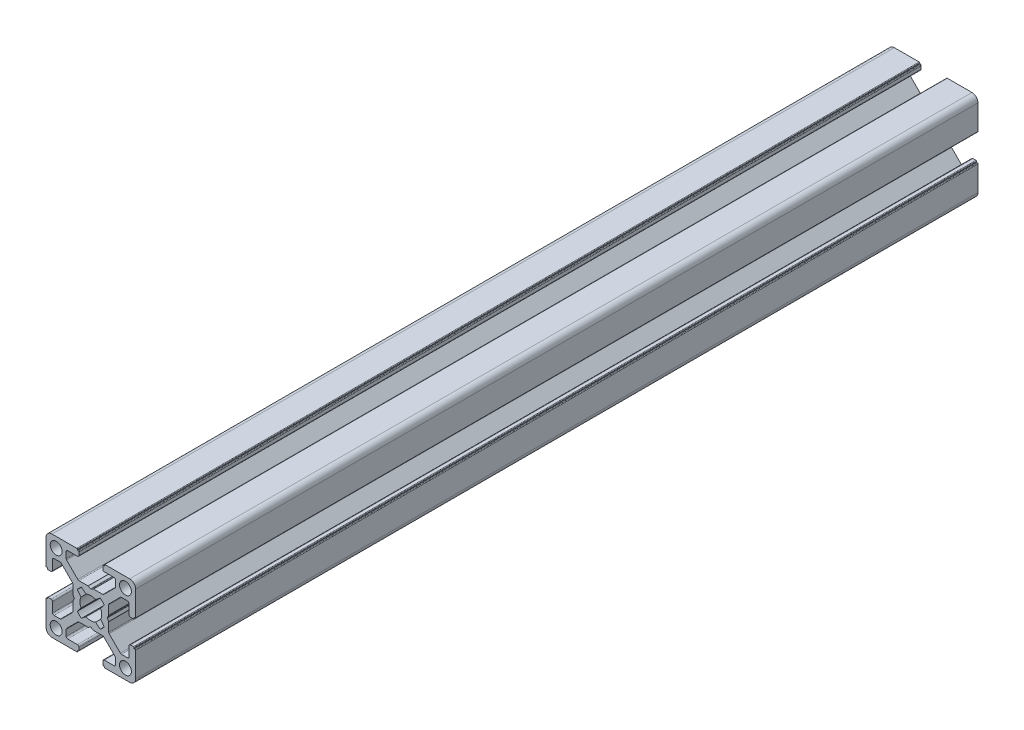
from build123d import *

# Parameters (mm, degrees)
CROQUIS1_R              = 2
SALIENTE_EXTRUIR1_DEPTH = 282


with BuildPart() as part:
    # Croquis1 → Saliente-Extruir1 (new body)
    with BuildSketch(Plane.XY.offset(1000)):
        with BuildLine():
            Line((9.800000436, -10.500000436), (10.100000436, -10.500000436))
            ThreePointArc((10.100000436, -10.500000436), (10.241421792, -10.441421792), (10.300000436, -10.300000436))
            Line((10.300000436, -10.300000436), (10.300000436, -2))
            ThreePointArc((10.300000436, -2), (9.714213998, -0.585786438), (8.300000436, 0))
            Line((8.300000436, 0), (0, 0))
            ThreePointArc((0, 0), (-0.141421356, -0.058578644), (-0.2, -0.2))
            Line((-0.2, -0.2), (-0.2, -0.5))
            Line((-0.2, -0.5), (-0.49999919, -0.5))
            ThreePointArc((-0.49999919, -0.5), (-0.641420811, -0.558578753), (-0.699999564, -0.700000374))
            Line((-0.699999564, -0.700000374), (-0.699999564, -1.700000763))
            ThreePointArc((-0.699999564, -1.700000763), (-0.553552955, -2.053554154), (-0.199999564, -2.200000763))
            Line((-0.199999564, -2.200000763), (3.050000763, -2.200000763))
            ThreePointArc((3.050000763, -2.200000763), (3.403554154, -2.346447372), (3.550000763, -2.700000763))
            Line((3.550000763, -2.700000763), (3.550000763, -4.743055509))
            ThreePointArc((3.550000763, -4.743055509), (3.511993279, -4.934269826), (3.403749103, -5.096413843))
            Line((3.403749103, -5.096413843), (-0.349053376, -8.853358334))
            ThreePointArc((-0.349053376, -8.853358334), (-0.511332616, -8.961886981), (-0.702801716, -9))
            Line((-0.702801716, -9), (-3.746809419, -9))
            ThreePointArc((-3.746809419, -9), (-3.798212795, -9.006718618), (-3.846162576, -9.026423071))
            Line((-3.846162576, -9.026423071), (-4.600646407, -9.458279719))
            ThreePointArc((-4.600646407, -9.458279719), (-4.699999564, -9.48470279), (-4.799352721, -9.458279719))
            Line((-4.799352721, -9.458279719), (-5.553836552, -9.026423071))
            ThreePointArc((-5.553836552, -9.026423071), (-5.601786333, -9.006718618), (-5.653189709, -9))
            Line((-5.653189709, -9), (-8.697197412, -9))
            ThreePointArc((-8.697197412, -9), (-8.888666513, -8.961886981), (-9.050945752, -8.853358334))
            Line((-9.050945752, -8.853358334), (-12.803748231, -5.096413843))
            ThreePointArc((-12.803748231, -5.096413843), (-12.911992407, -4.934269826), (-12.949999891, -4.743055509))
            Line((-12.949999891, -4.743055509), (-12.949999891, -2.700000763))
            ThreePointArc((-12.949999891, -2.700000763), (-12.803553282, -2.346447372), (-12.449999891, -2.200000763))
            Line((-12.449999891, -2.200000763), (-9.199999564, -2.200000763))
            ThreePointArc((-9.199999564, -2.200000763), (-8.846446173, -2.053554154), (-8.699999564, -1.700000763))
            Line((-8.699999564, -1.700000763), (-8.699999564, -0.700000374))
            ThreePointArc((-8.699999564, -0.700000374), (-8.758578317, -0.558578753), (-8.899999938, -0.5))
            Line((-8.899999938, -0.5), (-9.199999128, -0.5))
            Line((-9.199999128, -0.5), (-9.199999128, -0.2))
            ThreePointArc((-9.199999128, -0.2), (-9.258577772, -0.058578644), (-9.399999128, 0))
            Line((-9.399999128, 0), (-17.699999564, 0))
            ThreePointArc((-17.699999564, 0), (-19.114213126, -0.585786438), (-19.699999564, -2))
            Line((-19.699999564, -2), (-19.699999564, -10.300000436))
            ThreePointArc((-19.699999564, -10.300000436), (-19.64142092, -10.441421792), (-19.499999564, -10.500000436))
            Line((-19.499999564, -10.500000436), (-19.199999564, -10.500000436))
            Line((-19.199999564, -10.500000436), (-19.199999564, -10.799999627))
            ThreePointArc((-19.199999564, -10.799999627), (-19.141420811, -10.941421247), (-18.99999919, -11))
            Line((-18.99999919, -11), (-17.999998801, -11))
            ThreePointArc((-17.999998801, -11), (-17.64644541, -10.853553391), (-17.499998801, -10.5))
            Line((-17.499998801, -10.5), (-17.499998801, -7.249999673))
            ThreePointArc((-17.499998801, -7.249999673), (-17.353552192, -6.896446283), (-16.999998801, -6.749999673))
            Line((-16.999998801, -6.749999673), (-14.956944055, -6.749999673))
            ThreePointArc((-14.956944055, -6.749999673), (-14.765729738, -6.788007157), (-14.603585721, -6.896251334))
            Line((-14.603585721, -6.896251334), (-10.84664123, -10.649053813))
            ThreePointArc((-10.84664123, -10.649053813), (-10.738112583, -10.811333052), (-10.699999564, -11.002802152))
            Line((-10.699999564, -11.002802152), (-10.699999564, -14.046809855))
            ThreePointArc((-10.699999564, -14.046809855), (-10.693280947, -14.098213232), (-10.673576493, -14.146163012))
            Line((-10.673576493, -14.146163012), (-10.241719845, -14.900646843))
            ThreePointArc((-10.241719845, -14.900646843), (-10.215296774, -15), (-10.241719845, -15.099353157))
            Line((-10.241719845, -15.099353157), (-10.673576493, -15.853836988))
            ThreePointArc((-10.673576493, -15.853836988), (-10.693280947, -15.901786769), (-10.699999564, -15.953190146))
            Line((-10.699999564, -15.953190146), (-10.699999564, -18.997197848))
            ThreePointArc((-10.699999564, -18.997197848), (-10.738112583, -19.188666949), (-10.84664123, -19.350946188))
            Line((-10.84664123, -19.350946188), (-14.603585721, -23.103748667))
            ThreePointArc((-14.603585721, -23.103748667), (-14.765729738, -23.211992843), (-14.956944055, -23.250000327))
            Line((-14.956944055, -23.250000327), (-16.999998801, -23.250000327))
            ThreePointArc((-16.999998801, -23.250000327), (-17.353552192, -23.103553718), (-17.499998801, -22.750000327))
            Line((-17.499998801, -22.750000327), (-17.499998801, -19.5))
            ThreePointArc((-17.499998801, -19.5), (-17.64644541, -19.14644661), (-17.999998801, -19))
            Line((-17.999998801, -19), (-18.99999919, -19))
            ThreePointArc((-18.99999919, -19), (-19.141420811, -19.058578753), (-19.199999564, -19.200000374))
            Line((-19.199999564, -19.200000374), (-19.199999564, -19.499999564))
            Line((-19.199999564, -19.499999564), (-19.499999564, -19.499999564))
            ThreePointArc((-19.499999564, -19.499999564), (-19.64142092, -19.558578208), (-19.699999564, -19.699999564))
            Line((-19.699999564, -19.699999564), (-19.699999564, -28))
            ThreePointArc((-19.699999564, -28), (-19.114213126, -29.414213563), (-17.699999564, -30))
            Line((-17.699999564, -30), (-9.399999128, -30))
            ThreePointArc((-9.399999128, -30), (-9.258577772, -29.941421356), (-9.199999128, -29.8))
            Line((-9.199999128, -29.8), (-9.199999128, -29.5))
            Line((-9.199999128, -29.5), (-8.899999938, -29.5))
            ThreePointArc((-8.899999938, -29.5), (-8.758578317, -29.441421247), (-8.699999564, -29.299999627))
            Line((-8.699999564, -29.299999627), (-8.699999564, -28.299999237))
            ThreePointArc((-8.699999564, -28.299999237), (-8.846446173, -27.946445847), (-9.199999564, -27.799999237))
            Line((-9.199999564, -27.799999237), (-12.449999891, -27.799999237))
            ThreePointArc((-12.449999891, -27.799999237), (-12.803553282, -27.653552628), (-12.949999891, -27.299999237))
            Line((-12.949999891, -27.299999237), (-12.949999891, -25.256944491))
            ThreePointArc((-12.949999891, -25.256944491), (-12.911992407, -25.065730174), (-12.803748231, -24.903586157))
            Line((-12.803748231, -24.903586157), (-9.050945752, -21.146641666))
            ThreePointArc((-9.050945752, -21.146641666), (-8.888666513, -21.038113019), (-8.697197412, -21))
            Line((-8.697197412, -21), (-5.653189709, -21))
            ThreePointArc((-5.653189709, -21), (-5.601786333, -20.993281383), (-5.553836552, -20.973576929))
            Line((-5.553836552, -20.973576929), (-4.799352721, -20.541720281))
            ThreePointArc((-4.799352721, -20.541720281), (-4.699999564, -20.51529721), (-4.600646407, -20.541720281))
            Line((-4.600646407, -20.541720281), (-3.846162576, -20.973576929))
            ThreePointArc((-3.846162576, -20.973576929), (-3.798212795, -20.993281383), (-3.746809419, -21))
            Line((-3.746809419, -21), (-0.702801716, -21))
            ThreePointArc((-0.702801716, -21), (-0.511332616, -21.038113019), (-0.349053377, -21.146641666))
            Line((-0.349053377, -21.146641666), (3.403749103, -24.903586157))
            ThreePointArc((3.403749103, -24.903586157), (3.511993279, -25.065730174), (3.550000763, -25.256944491))
            Line((3.550000763, -25.256944491), (3.550000763, -27.299999237))
            ThreePointArc((3.550000763, -27.299999237), (3.403554154, -27.653552628), (3.050000763, -27.799999237))
            Line((3.050000763, -27.799999237), (-0.199999564, -27.799999237))
            ThreePointArc((-0.199999564, -27.799999237), (-0.553552955, -27.946445847), (-0.699999564, -28.299999237))
            Line((-0.699999564, -28.299999237), (-0.699999564, -29.299999627))
            ThreePointArc((-0.699999564, -29.299999627), (-0.641420811, -29.441421247), (-0.49999919, -29.5))
            Line((-0.49999919, -29.5), (-0.2, -29.5))
            Line((-0.2, -29.5), (-0.2, -29.8))
            ThreePointArc((-0.2, -29.8), (-0.141421356, -29.941421356), (0, -30))
            Line((0, -30), (8.300000436, -30))
            ThreePointArc((8.300000436, -30), (9.714213998, -29.414213563), (10.300000436, -28))
            Line((10.300000436, -28), (10.300000436, -19.699999564))
            ThreePointArc((10.300000436, -19.699999564), (10.241421792, -19.558578208), (10.100000436, -19.499999564))
            Line((10.100000436, -19.499999564), (9.800000436, -19.499999564))
            Line((9.800000436, -19.499999564), (9.800000436, -19.200000374))
            ThreePointArc((9.800000436, -19.200000374), (9.741421683, -19.058578753), (9.600000062, -19))
            Line((9.600000062, -19), (8.599999673, -19))
            ThreePointArc((8.599999673, -19), (8.246446283, -19.14644661), (8.099999673, -19.5))
            Line((8.099999673, -19.5), (8.099999673, -22.750000327))
            ThreePointArc((8.099999673, -22.750000327), (7.953553064, -23.103553718), (7.599999673, -23.250000327))
            Line((7.599999673, -23.250000327), (5.556944927, -23.250000327))
            ThreePointArc((5.556944927, -23.250000327), (5.36573061, -23.211992843), (5.203586593, -23.103748667))
            Line((5.203586593, -23.103748667), (1.446642102, -19.350946188))
            ThreePointArc((1.446642102, -19.350946188), (1.338113455, -19.188666949), (1.300000436, -18.997197848))
            Line((1.300000436, -18.997197848), (1.300000436, -15.953190145))
            ThreePointArc((1.300000436, -15.953190145), (1.293281819, -15.901786769), (1.273577365, -15.853836988))
            Line((1.273577365, -15.853836988), (0.841720717, -15.099353157))
            ThreePointArc((0.841720717, -15.099353157), (0.815297646, -15), (0.841720717, -14.900646843))
            Line((0.841720717, -14.900646843), (1.273577365, -14.146163012))
            ThreePointArc((1.273577365, -14.146163012), (1.293281819, -14.098213231), (1.300000436, -14.046809855))
            Line((1.300000436, -14.046809855), (1.300000436, -11.002802152))
            ThreePointArc((1.300000436, -11.002802152), (1.338113455, -10.811333052), (1.446642102, -10.649053813))
            Line((1.446642102, -10.649053813), (5.203586593, -6.896251334))
            ThreePointArc((5.203586593, -6.896251334), (5.36573061, -6.788007157), (5.556944927, -6.749999673))
            Line((5.556944927, -6.749999673), (7.599999673, -6.749999673))
            ThreePointArc((7.599999673, -6.749999673), (7.953553064, -6.896446283), (8.099999673, -7.249999673))
            Line((8.099999673, -7.249999673), (8.099999673, -10.5))
            ThreePointArc((8.099999673, -10.5), (8.246446283, -10.853553391), (8.599999673, -11))
            Line((8.599999673, -11), (9.600000062, -11))
            ThreePointArc((9.600000062, -11), (9.741421683, -10.941421247), (9.800000436, -10.799999627))
            Line((9.800000436, -10.799999627), (9.800000436, -10.500000436))
        make_face()
        with Locations((-16.300000272, -3.399999983)):
            Circle(CROQUIS1_R, mode=Mode.SUBTRACT)
        with Locations((6.900001145, -3.399999983)):
            Circle(CROQUIS1_R, mode=Mode.SUBTRACT)
        with Locations((-16.300000272, -26.600000017)):
            Circle(CROQUIS1_R, mode=Mode.SUBTRACT)
        with Locations((6.900001145, -26.600000017)):
            Circle(CROQUIS1_R, mode=Mode.SUBTRACT)
        with BuildLine():
            Line((-7.835928976, -10.481599097), (-6.300129088, -11.719438233))
            ThreePointArc((-6.300129088, -11.719438233), (-4.699999564, -11.35), (-3.09987004, -11.719438233))
            Line((-3.09987004, -11.719438233), (-1.564070152, -10.481599097))
            ThreePointArc((-1.564070152, -10.481599097), (-0.818997305, -11.10284444), (-0.194662672, -11.845330527))
            Line((-0.194662672, -11.845330527), (-1.419437832, -13.399870404))
            ThreePointArc((-1.419437832, -13.399870404), (-1.049999564, -15), (-1.419437832, -16.600129597))
            Line((-1.419437832, -16.600129597), (-0.194662672, -18.154669473))
            ThreePointArc((-0.194662672, -18.154669473), (-0.818997305, -18.897155561), (-1.564070152, -19.518400903))
            Line((-1.564070152, -19.518400903), (-3.09987004, -18.280561767))
            ThreePointArc((-3.09987004, -18.280561767), (-4.699999564, -18.65), (-6.300129088, -18.280561767))
            Line((-6.300129088, -18.280561767), (-7.835928976, -19.518400903))
            ThreePointArc((-7.835928976, -19.518400903), (-8.581001823, -18.897155561), (-9.205336456, -18.154669473))
            Line((-9.205336456, -18.154669473), (-7.980561295, -16.600129597))
            ThreePointArc((-7.980561295, -16.600129597), (-8.349999564, -15), (-7.980561296, -13.399870404))
            Line((-7.980561296, -13.399870404), (-9.205336456, -11.845330527))
            ThreePointArc((-9.205336456, -11.845330527), (-8.581001823, -11.10284444), (-7.835928976, -10.481599097))
        make_face(mode=Mode.SUBTRACT)
    extrude(amount=-SALIENTE_EXTRUIR1_DEPTH)


solid = part.part
